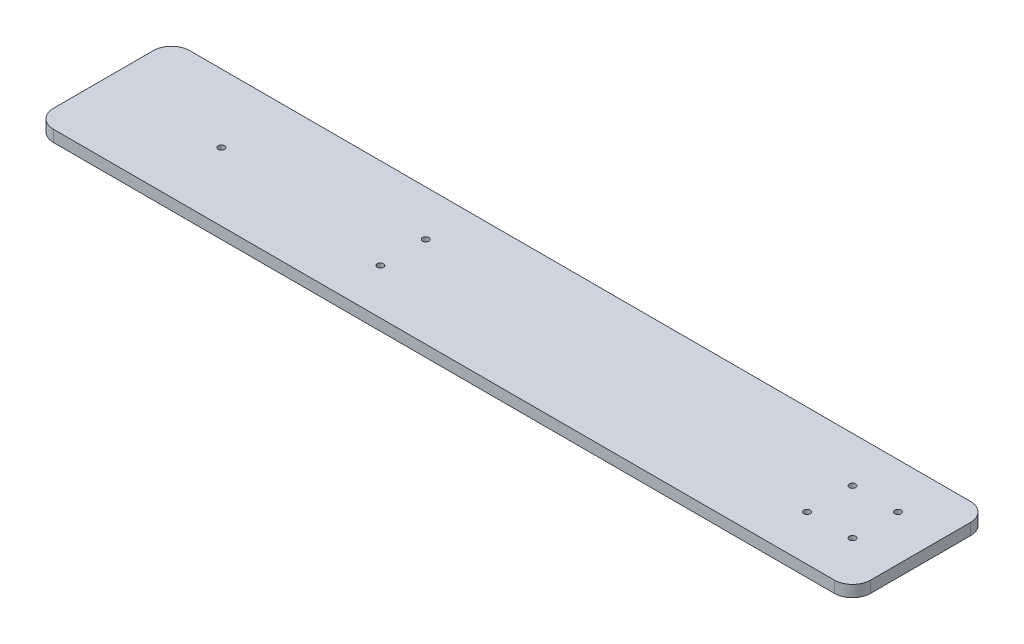
from build123d import *

# Parameters (mm, degrees)
SKETCH12_W                = 450
SKETCH12_H                = 75
BOSS_EXTRUDE2_DEPTH       = 6.35
SKETCH13_R                = 1.75
CUT_EXTRUDE1_DEPTH        = 7.35
LPATTERN1_COUNT           = 2
LPATTERN1_PITCH           = 25
LPATTERN2_COUNT           = 2
LPATTERN2_PITCH           = 25
LPATTERN2_COPY_1_SKETCH_R = 1.75
LPATTERN2_COPY_1_DEPTH    = 7.35
SKETCH15_R                = 1.75
CUT_EXTRUDE2_DEPTH        = 7.35
FILLET1_R                 = 10
SKETCH17_R                = 1.75
CUT_EXTRUDE3_DEPTH        = 7.35


with BuildPart() as part:
    # Sketch12 → Boss-Extrude2 (new body)
    with BuildSketch(Plane(origin=(0, 0, 0), x_dir=(1, 0, 0), z_dir=(0, 1, 0))):
        Rectangle(SKETCH12_W, SKETCH12_H)
    extrude(amount=BOSS_EXTRUDE2_DEPTH)

    # Sketch13 → Cut-Extrude1 (cut, through all)
    with BuildSketch(Plane.XZ):
        with Locations((175, -12.5)):
            Circle(SKETCH13_R)
    cut_extrude1 = extrude(amount=-CUT_EXTRUDE1_DEPTH, mode=Mode.SUBTRACT)

    # LPattern1: Cut-Extrude1 ×2
    with Locations(*[(i * LPATTERN1_PITCH, 0, 0) for i in range(1, LPATTERN1_COUNT)]):
        add(cut_extrude1, mode=Mode.SUBTRACT)

    # LPattern2: Cut-Extrude1 ×2
    with Locations(*[(0, 0, i * LPATTERN2_PITCH) for i in range(1, LPATTERN2_COUNT)]):
        add(cut_extrude1, mode=Mode.SUBTRACT)

    # LPattern2 copy 1 sketch → LPattern2 copy 1 (cut, through all)
    with BuildSketch(Plane(origin=(25, 0, 25), x_dir=(1, 0, 0), z_dir=(0, -1, 0))):
        with Locations((175, -12.5)):
            Circle(LPATTERN2_COPY_1_SKETCH_R)
    extrude(amount=-LPATTERN2_COPY_1_DEPTH, mode=Mode.SUBTRACT)

    # Sketch15 → Cut-Extrude2 (cut, through all)
    with BuildSketch(Plane.XZ):
        with Locations((-160, 0)):
            Circle(SKETCH15_R)
    extrude(amount=-CUT_EXTRUDE2_DEPTH, mode=Mode.SUBTRACT)

    # Fillet1
    fillet1_edges = [part.edges().sort_by_distance(p)[0] for p in [
        (225, 3.175, 37.5),
        (-225, 3.175, 37.5),
        (-225, 3.175, -37.5),
        (225, 3.175, -37.5),
    ]]
    fillet(fillet1_edges, radius=FILLET1_R)

    # Sketch17 → Cut-Extrude3 (cut, through all)
    with BuildSketch(Plane(origin=(0, 6.35, 0), x_dir=(1, 0, 0), z_dir=(0, 1, 0))):
        with Locations((-60, 12.5)):
            Circle(SKETCH17_R)
        with Locations((-60, -12.5)):
            Circle(SKETCH17_R)
    extrude(amount=-CUT_EXTRUDE3_DEPTH, mode=Mode.SUBTRACT)


solid = part.part
